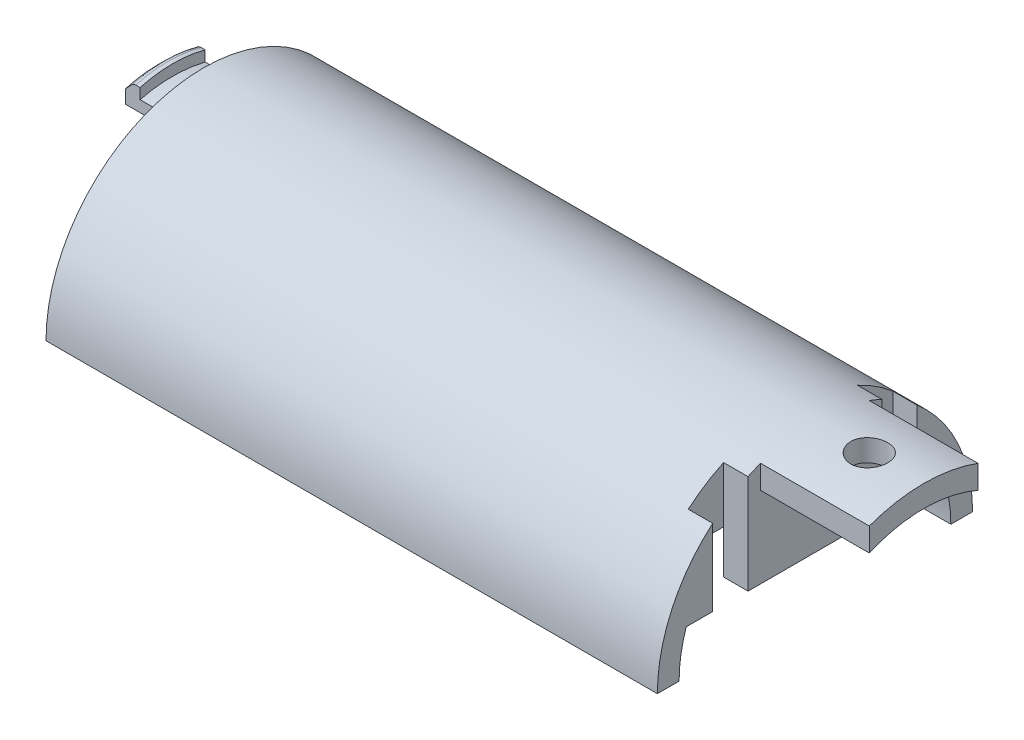
from build123d import *

# Parameters (mm, degrees)
SALIENTE_EXTRUIR1_DEPTH  = 30.875
SALIENTE_EXTRUIR2_DEPTH  = 2
SALIENTE_EXTRUIR3_DEPTH  = 20
SALIENTE_EXTRUIR4_START  = 3
SALIENTE_EXTRUIR4_DEPTH  = 3
CROQUIS6_W               = 2
CROQUIS6_H               = 6
SALIENTE_EXTRUIR6_DEPTH  = 2.5
CORTAR_EXTRUIR1_REACH    = 67.066
SALIENTE_EXTRUIR7_START  = 4.2
SALIENTE_EXTRUIR7_DEPTH  = 4.2
SALIENTE_EXTRUIR9_DEPTH  = 1.35
CHAFL_N3_SIZE            = 0.75
REDONDEO1_R              = 0.5
CHAFL_N4_SIZE            = 1
CORTAR_EXTRUIR2_DEPTH    = 5.5
SALIENTE_EXTRUIR10_START = 10
SALIENTE_EXTRUIR10_DEPTH = 10
CORTAR_EXTRUIR3_REACH    = 42.889
CROQUIS11_R              = 1.7
CROQUIS14_W              = 2.25
CROQUIS14_H              = 3.25
CORTAR_EXTRUIR6_DEPTH    = 40.647076022


with BuildPart() as part:
    # Croquis2 → Saliente-Extruir1 (new, symmetric)
    with BuildSketch(Plane.YZ):
        with BuildLine():
            Line((0, -12.5), (0, -14.5))
            ThreePointArc((0, -14.5), (14.5, 0), (0, 14.5))
            Line((0, 14.5), (0, 12.5))
            ThreePointArc((0, 12.5), (12.5, 0), (0, -12.5))
        make_face()
    extrude(amount=SALIENTE_EXTRUIR1_DEPTH, both=True)

    # Croquis3 → Saliente-Extruir2 (add)
    with BuildSketch(Plane(origin=(-21.625, 0, 0), x_dir=(0, 0, -1), z_dir=(1, 0, 0))):
        with BuildLine():
            Line((-12.5, 0), (-3.75, 0))
            ThreePointArc((-3.75, 0), (0, 3.75), (3.75, 0))
            Line((3.75, 0), (12.5, 0))
            ThreePointArc((12.5, 0), (0, 12.5), (-12.5, 0))
        make_face()
    extrude(amount=-SALIENTE_EXTRUIR2_DEPTH)

    # Croquis4 → Saliente-Extruir3 (add)
    with BuildSketch(Plane(origin=(23.125, 0, 0), x_dir=(0, 0, -1), z_dir=(1, 0, 0))):
        with BuildLine():
            ThreePointArc((9.604686356, 8), (0, 12.5), (-9.604686356, 8))
            Line((-9.604686356, 8), (9.604686356, 8))
        make_face()
    extrude(amount=-SALIENTE_EXTRUIR3_DEPTH)

    # Croquis4_4 → Saliente-Extruir4 (add)
    with BuildSketch(Plane(origin=(23.125, 0, 0), x_dir=(0, 0, -1), z_dir=(1, 0, 0)).offset(SALIENTE_EXTRUIR4_START)):
        with BuildLine():
            Line((-11.842719282, 4), (11.842719282, 4))
            ThreePointArc((11.842719282, 4), (0, 12.5), (-11.842719282, 4))
        make_face()
    extrude(amount=-SALIENTE_EXTRUIR4_DEPTH)

    # Croquis6 → Saliente-Extruir6 (add)
    with BuildSketch(Plane(origin=(0, 13.5, 0), x_dir=(-1, 0, 0), z_dir=(0, 1, 0))):
        with Locations((29.875, 0)):
            Rectangle(CROQUIS6_W, CROQUIS6_H)
    extrude(amount=-SALIENTE_EXTRUIR6_DEPTH)

    # Croquis7 → Cortar-Extruir1 (cut, up to next)
    with BuildSketch(Plane(origin=(-30.875, 0, 0), x_dir=(0, -1, 0), z_dir=(-1, 0, 0)), mode=Mode.PRIVATE) as cortar_extruir1_sk1:
        with BuildLine():
            Line((-11, -3), (-11, 3))
            ThreePointArc((-11, 3), (-11.401754251, 0), (-11, -3))
        make_face()
    cortar_extruir1_tool1 = extrude(cortar_extruir1_sk1.sketch, amount=-CORTAR_EXTRUIR1_REACH, mode=Mode.PRIVATE) & part.part
    add(cortar_extruir1_tool1.solids().sort_by_distance((-30.875, 11.160947, 0))[0], mode=Mode.SUBTRACT)

    # Croquis7_4 → Saliente-Extruir7 (add)
    with BuildSketch(Plane(origin=(-30.875, 0, 0), x_dir=(0, -1, 0), z_dir=(-1, 0, 0)).offset(SALIENTE_EXTRUIR7_START)):
        with BuildLine():
            ThreePointArc((-11, -3), (-11.401754251, 0), (-11, 3))
            Line((-11, 3), (-12.033432948, 3))
            ThreePointArc((-12.033432948, 3), (-12.401754251, 0), (-12.033432948, -3))
            Line((-12.033432948, -3), (-11, -3))
        make_face()
    extrude(amount=-SALIENTE_EXTRUIR7_DEPTH)

    # Croquis8 → Saliente-Extruir9 (add)
    with BuildSketch(Plane(origin=(-35.075, 0, 0), x_dir=(0, -1, 0), z_dir=(-1, 0, 0))):
        with BuildLine():
            Line((-11, 3), (-13, 3))
            ThreePointArc((-13, 3), (-13.401754251, 0), (-13, -3))
            Line((-13, -3), (-11, -3))
            ThreePointArc((-11, -3), (-11.401754251, 0), (-11, 3))
        make_face()
    extrude(amount=-SALIENTE_EXTRUIR9_DEPTH)

    # Chaflán3
    chafl_n3_edges = [part.edges().sort_by_distance(p)[0] for p in [
        (-35.075, 13.401754251, 0),
    ]]
    chamfer(chafl_n3_edges, length=CHAFL_N3_SIZE)

    # Redondeo1
    redondeo1_edges = [part.edges().sort_by_distance(p)[0] for p in [
        (-34.325, 13.401754251, 0),
    ]]
    fillet(redondeo1_edges, radius=REDONDEO1_R)

    # Chaflán4
    chafl_n4_edges = [part.edges().sort_by_distance(p)[0] for p in [
        (-28.875, 12.5, 0),
    ]]
    chamfer(chafl_n4_edges, length=CHAFL_N4_SIZE)

    # Croquis9 → Cortar-Extruir2 (cut)
    with BuildSketch(Plane.YZ.offset(30.875)):
        with BuildLine():
            Line((4, 11.842719282), (4, -11.842719282))
            ThreePointArc((4, -11.842719282), (2.026821276, -12.33458534), (0, -12.5))
            Line((0, -12.5), (0, -14.5))
            ThreePointArc((0, -14.5), (14.5, 0), (0, 14.5))
            Line((0, 14.5), (0, 12.5))
            ThreePointArc((0, 12.5), (2.026821276, 12.33458534), (4, 11.842719282))
        make_face()
    extrude(amount=-CORTAR_EXTRUIR2_DEPTH, mode=Mode.SUBTRACT)

    # Croquis10 → Saliente-Extruir10 (add)
    with BuildSketch(Plane.YZ.offset(25.375).offset(SALIENTE_EXTRUIR10_START)):
        with BuildLine():
            Line((11.456439237, 5), (13.610657589, 5))
            ThreePointArc((13.610657589, 5), (14.5, 0), (13.610657589, -5))
            Line((13.610657589, -5), (11.456439237, -5))
            ThreePointArc((11.456439237, -5), (12.5, 0), (11.456439237, 5))
        make_face()
    extrude(amount=-SALIENTE_EXTRUIR10_DEPTH)

    # Croquis11 → Cortar-Extruir3 (cut, up to next)
    with BuildSketch(Plane(origin=(0, 14.5, 0), x_dir=(-1, 0, 0), z_dir=(0, 1, 0)), mode=Mode.PRIVATE) as cortar_extruir3_sk1:
        with Locations((-30.375, 0)):
            Circle(CROQUIS11_R)
    cortar_extruir3_tool1 = extrude(cortar_extruir3_sk1.sketch, amount=-CORTAR_EXTRUIR3_REACH, mode=Mode.PRIVATE) & part.part
    add(cortar_extruir3_tool1.solids().sort_by_distance((30.375, 14.5, 0))[0], mode=Mode.SUBTRACT)

    # Croquis14 → Cortar-Extruir6 (cut, through all)
    with BuildSketch(Plane.XZ.offset(-4)):
        with Locations((24.25, 7.785)):
            Rectangle(CROQUIS14_W, CROQUIS14_H)
        with Locations((24.25, -7.785)):
            Rectangle(CROQUIS14_W, CROQUIS14_H)
    extrude(amount=-CORTAR_EXTRUIR6_DEPTH, mode=Mode.SUBTRACT)


solid = part.part
